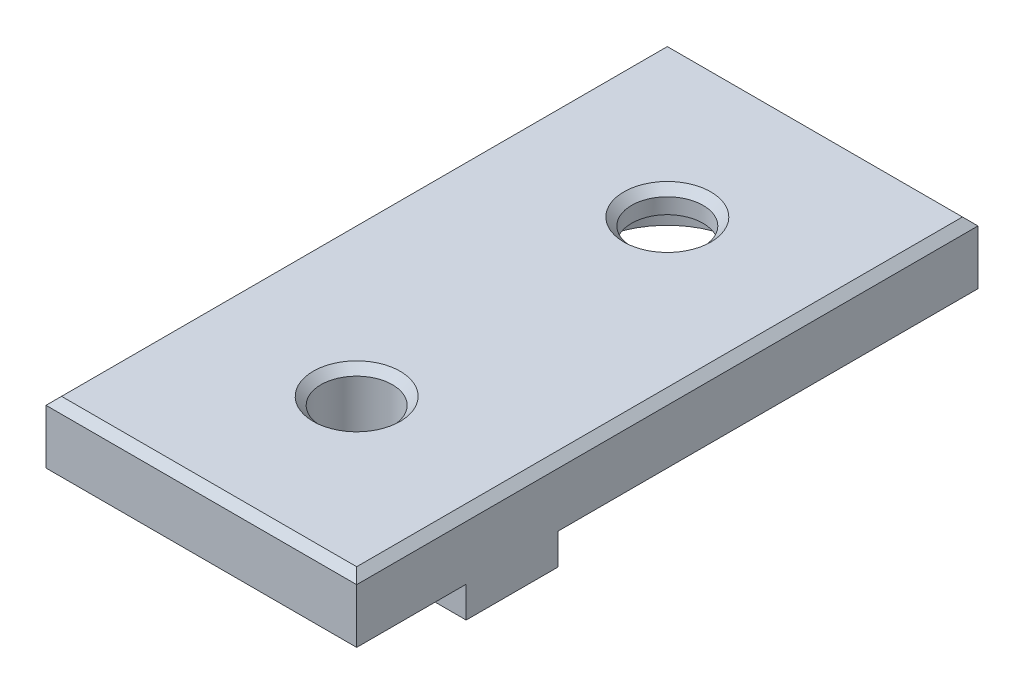
from build123d import *

# Parameters (mm, degrees)
ESBO_O1_W                  = 20
ESBO_O1_H                  = 40
RESSALTO_EXTRUS_O1_DEPTH   = 4
ESBO_O2_R                  = 2.3
CORTE_EXTRUS_O1_DEPTH      = 1
CORTE_EXTRUS_O1_DEPTH_BACK = 5
ESBO_O3_W                  = 7
ESBO_O3_H                  = 5.9
RESSALTO_EXTRUS_O2_DEPTH   = 2
CHANFRO1_SIZE              = 0.5
ESBO_O4_R                  = 5
CORTE_EXTRUS_O2_DEPTH      = 2.5


with BuildPart() as part:
    # Esboço1 → Ressalto-extrusão1 (new body)
    with BuildSketch(Plane(origin=(0, 0, 0), x_dir=(1, 0, 0), z_dir=(0, 1, 0))):
        Rectangle(ESBO_O1_W, ESBO_O1_H)
    extrude(amount=RESSALTO_EXTRUS_O1_DEPTH)

    # Esboço2 → Corte-extrusão1 (cut, two sides)
    with BuildSketch(Plane(origin=(0, 4, 0), x_dir=(1, 0, 0), z_dir=(0, 1, 0))) as corte_extrus_o1_sk:
        with Locations((0, 10)):
            Circle(ESBO_O2_R)
        with Locations((0, -10)):
            Circle(ESBO_O2_R)
    extrude(amount=CORTE_EXTRUS_O1_DEPTH, mode=Mode.SUBTRACT)
    extrude(corte_extrus_o1_sk.sketch, amount=-CORTE_EXTRUS_O1_DEPTH_BACK, mode=Mode.SUBTRACT)

    # Esboço3 → Ressalto-extrusão2 (add)
    with BuildSketch(Plane.XZ):
        with Locations((6.5, 10)):
            Rectangle(ESBO_O3_W, ESBO_O3_H)
        with Locations((-6.5, 10)):
            Rectangle(ESBO_O3_W, ESBO_O3_H)
    extrude(amount=RESSALTO_EXTRUS_O2_DEPTH)

    # Chanfro1
    chanfro1_edges = [part.edges().sort_by_distance(p)[0] for p in [
        (-10, 4, 0),
        (0, 4, 20),
        (-2.3, 4, -10),
        (-2.3, 4, 10),
        (10, 4, 0),
        (0, 4, -20),
    ]]
    chamfer(chanfro1_edges, length=CHANFRO1_SIZE)

    # Esboço4 → Corte-extrusão2 (cut)
    with BuildSketch(Plane.XZ):
        with Locations((0, -10)):
            Circle(ESBO_O4_R)
    extrude(amount=-CORTE_EXTRUS_O2_DEPTH, mode=Mode.SUBTRACT)


solid = part.part
